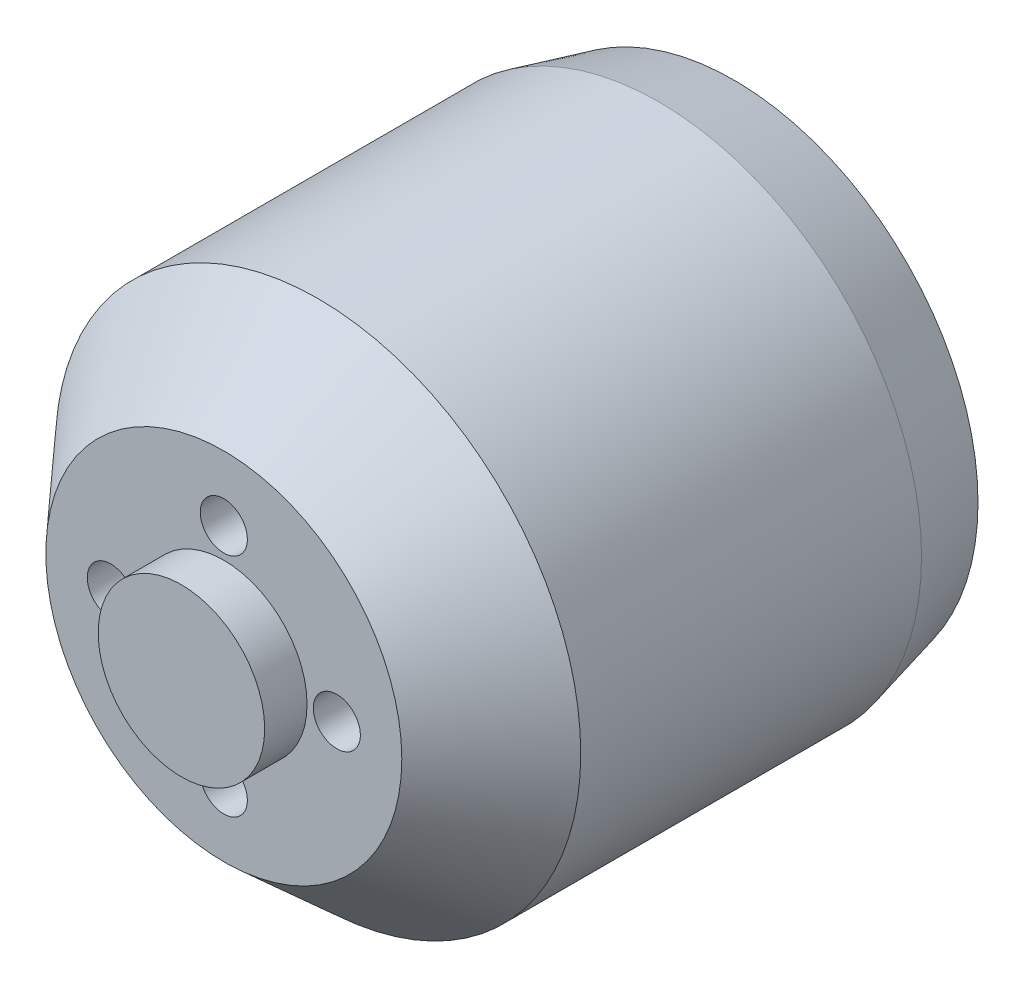
from build123d import *

# Parameters (mm, degrees)
SKETCH1_R           = 13.95
BOSS_EXTRUDE1_DEPTH = 29.34
SKETCH2_R           = 13.95
SKETCH2_R_2         = 4.42
CUT_EXTRUDE1_DEPTH  = 2.25
CHAMFER1_SIZE       = 5
CHAMFER1_SIZE2      = 4.5
CHAMFER2_SIZE       = 1
CHAMFER2_SIZE2      = 4
SKETCH3_R           = 1.75
CUT_EXTRUDE2_DEPTH  = 3
SKETCH4_R           = 1.25
CUT_EXTRUDE3_DEPTH  = 3


with BuildPart() as part:
    # Sketch1 → Boss-Extrude1 (new body)
    with BuildSketch(Plane.XY):
        Circle(SKETCH1_R)
    extrude(amount=BOSS_EXTRUDE1_DEPTH)

    # Sketch2 → Cut-Extrude1 (cut)
    with BuildSketch(Plane.XY.offset(29.34)):
        Circle(SKETCH2_R)
        Circle(SKETCH2_R_2, mode=Mode.SUBTRACT)
    extrude(amount=-CUT_EXTRUDE1_DEPTH, mode=Mode.SUBTRACT)

    # Chamfer1
    chamfer1_edges = [part.edges().sort_by_distance(p)[0] for p in [
        (-13.95, 0, 27.09),
    ]]
    chamfer1_side = [part.faces().sort_by_distance(p)[0] for p in [
        (-13.95, 0, 13.545),
    ]]
    chamfer(chamfer1_edges, length=CHAMFER1_SIZE, length2=CHAMFER1_SIZE2, reference=chamfer1_side[0])

    # Chamfer2
    chamfer2_edges = [part.edges().sort_by_distance(p)[0] for p in [
        (-13.95, 0, 0),
    ]]
    chamfer2_side = [part.faces().sort_by_distance(p)[0] for p in [
        (0, 0, 0),
    ]]
    chamfer(chamfer2_edges, length=CHAMFER2_SIZE, length2=CHAMFER2_SIZE2, reference=chamfer2_side[0])

    # Sketch3 → Cut-Extrude2 (cut)
    with BuildSketch(Plane(origin=(0, 0, 0), x_dir=(-1, 0, 0), z_dir=(0, 0, -1))):
        with Locations((8, 0)):
            Circle(SKETCH3_R)
        with Locations((-8, 0)):
            Circle(SKETCH3_R)
        with Locations((0, -9.5)):
            Circle(SKETCH3_R)
        with Locations((0, 9.5)):
            Circle(SKETCH3_R)
    extrude(amount=-CUT_EXTRUDE2_DEPTH, mode=Mode.SUBTRACT)

    # Sketch4 → Cut-Extrude3 (cut)
    with BuildSketch(Plane.XY.offset(27.09)):
        with Locations((0, 6)):
            Circle(SKETCH4_R)
        with Locations((6, 0)):
            Circle(SKETCH4_R)
        with Locations((0, -6)):
            Circle(SKETCH4_R)
        with Locations((-6, 0)):
            Circle(SKETCH4_R)
    extrude(amount=-CUT_EXTRUDE3_DEPTH, mode=Mode.SUBTRACT)


solid = part.part
